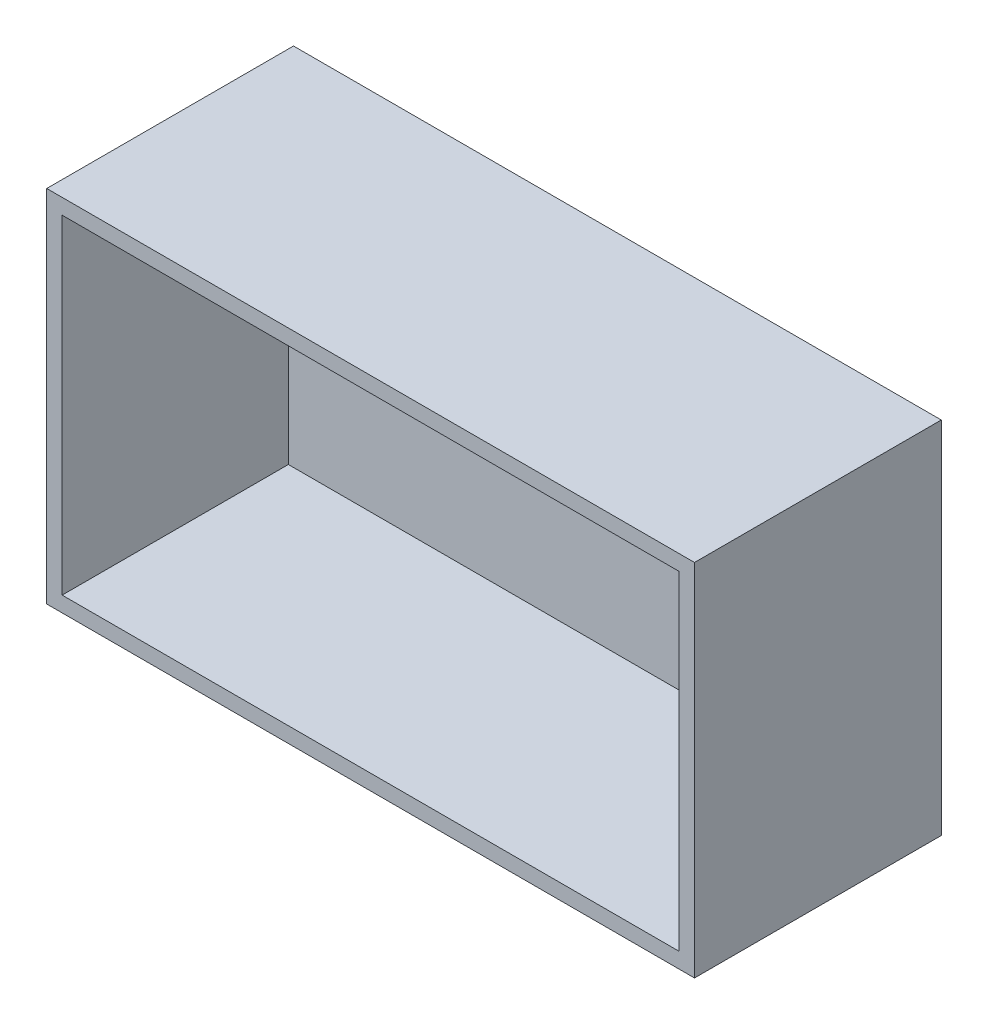
from build123d import *

# Parameters (mm, degrees)
SKETCH1_W           = 63
SKETCH1_H           = 35
BOSS_EXTRUDE1_DEPTH = 24
SKETCH3_W           = 60
SKETCH3_H           = 32
CUT_EXTRUDE1_DEPTH  = 22


with BuildPart() as part:
    # Sketch1 → Boss-Extrude1 (new body)
    with BuildSketch(Plane.XY):
        Rectangle(SKETCH1_W, SKETCH1_H)
    extrude(amount=BOSS_EXTRUDE1_DEPTH)

    # Sketch3 → Cut-Extrude1 (cut)
    with BuildSketch(Plane.XY.offset(24)):
        Rectangle(SKETCH3_W, SKETCH3_H)
    extrude(amount=-CUT_EXTRUDE1_DEPTH, mode=Mode.SUBTRACT)


solid = part.part
